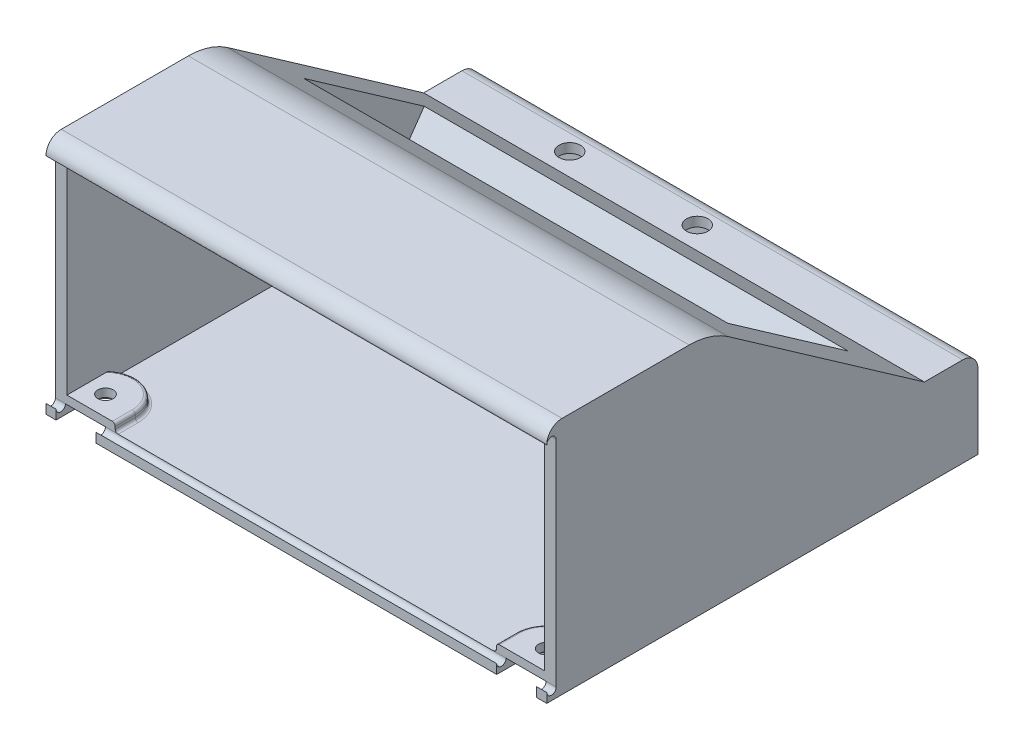
from build123d import *

# Parameters (mm, degrees)
BOSS_EXTRUDE1_DEPTH = 85
CUT_EXTRUDE1_START  = 1.95
CUT_EXTRUDE1_DEPTH  = 81.1
CUT_EXTRUDE5_REACH  = 51.22
SKETCH5_W           = 72
SKETCH5_H           = 25
SKETCH5_3_W         = 78
SKETCH5_3_H         = 31
SKETCH5_3_W_2       = 72
SKETCH5_3_H_2       = 25
BOSS_EXTRUDE3_DEPTH = 5.6
SKETCH6_R           = 1.825
CUT_EXTRUDE6_DEPTH  = 13.6
CUT_EXTRUDE7_REACH  = 87
SKETCH12_R          = 1.5
CUT_EXTRUDE10_DEPTH = 1.6
SKETCH12_5_R        = 1.5
SKETCH12_5_R_2      = 1.3
BOSS_EXTRUDE7_DEPTH = 3
SKETCH12_6_R        = 1.5
SKETCH12_6_R_2      = 1.3
CUT_EXTRUDE11_DEPTH = 1.6
CUT_EXTRUDE8_REACH  = 87
FILLET2_R           = 0.5


with BuildPart() as part:
    # Sketch1 → Boss-Extrude1 (new body)
    with BuildSketch(Plane(origin=(0, 0, 0), x_dir=(0, 0, -1), z_dir=(1, 0, 0))):
        with BuildLine():
            Line((-22.930528586, 36.4), (-22.930528586, -1.6))
            Line((-22.930528586, -1.6), (50.269471414, -1.6))
            Line((50.269471414, -1.6), (50.269471414, 11))
            ThreePointArc((50.269471414, 11), (49.507949045, 12.838477631), (47.669471414, 13.6))
            Line((47.669471414, 13.6), (41.173949476, 13.6))
            Line((41.173949476, 13.6), (7.895010815, 36.902163714))
            ThreePointArc((7.895010815, 36.902163714), (4.729711428, 38.463116629), (1.241524153, 39))
            Line((1.241524153, 39), (-20.330528586, 39))
            ThreePointArc((-20.330528586, 39), (-22.169006218, 38.238477631), (-22.930528586, 36.4))
        make_face()
    extrude(amount=BOSS_EXTRUDE1_DEPTH)

    # Sketch1_3 → Cut-Extrude1 (cut)
    with BuildSketch(Plane(origin=(0, 0, 0), x_dir=(0, 0, -1), z_dir=(1, 0, 0)).offset(CUT_EXTRUDE1_START)):
        with BuildLine():
            Line((48.669471414, 0), (48.669471414, 11))
            ThreePointArc((48.669471414, 11), (48.376578195, 11.707106781), (47.669471414, 12))
            Line((47.669471414, 12), (40.669471414, 12))
            Line((40.669471414, 12), (6.977288517, 35.591520443))
            ThreePointArc((6.977288517, 35.591520443), (4.248582149, 36.937169507), (1.241524153, 37.4))
            Line((1.241524153, 37.4), (-20.330528586, 37.4))
            ThreePointArc((-20.330528586, 37.4), (-21.037635368, 37.107106781), (-21.330528586, 36.4))
            Line((-21.330528586, 36.4), (-21.330528586, 0))
            Line((-21.330528586, 0), (48.669471414, 0))
        make_face()
    extrude(amount=CUT_EXTRUDE1_DEPTH, mode=Mode.SUBTRACT)

    # Sketch5 → Cut-Extrude5 (cut, up to next)
    with BuildSketch(Plane(origin=(0, 28.47116522, -19.935724509), x_dir=(1, 0, 0), z_dir=(0, 0.819152044, -0.573576436)), mode=Mode.PRIVATE) as cut_extrude5_sk1:
        with Locations((42.5, 5.614044021)):
            Rectangle(SKETCH5_W, SKETCH5_H)
    cut_extrude5_tool1 = extrude(cut_extrude5_sk1.sketch, amount=-CUT_EXTRUDE5_REACH, mode=Mode.PRIVATE) & part.part
    add(cut_extrude5_tool1.solids().sort_by_distance((42.5, 25.251082, -24.53448))[0], mode=Mode.SUBTRACT)

    # Sketch5_3 → Boss-Extrude3 (add)
    with BuildSketch(Plane(origin=(0, 28.47116522, -19.935724509), x_dir=(1, 0, 0), z_dir=(0, 0.819152044, -0.573576436))):
        with Locations((42.5, 5.614044021)):
            Rectangle(SKETCH5_3_W, SKETCH5_3_H)
        with Locations((42.5, 5.614044021)):
            Rectangle(SKETCH5_3_W_2, SKETCH5_3_H_2, mode=Mode.SUBTRACT)
    extrude(amount=-BOSS_EXTRUDE3_DEPTH)

    # Sketch6 → Cut-Extrude6 (cut)
    with BuildSketch(Plane(origin=(0, 13.6, 0), x_dir=(1, 0, 0), z_dir=(0, 1, 0))):
        with Locations((21, 44.969471414)):
            Circle(SKETCH6_R)
        with Locations((42.65, 44.969471414)):
            Circle(SKETCH6_R)
    extrude(amount=-CUT_EXTRUDE6_DEPTH, mode=Mode.SUBTRACT)

    # Sketch7 → Cut-Extrude7 (cut, up to next)
    with BuildSketch(Plane.ZY, mode=Mode.PRIVATE) as cut_extrude7_sk1:
        with BuildLine():
            Line((-12.869471414, 15.725), (-5.319471414, 15.725))
            ThreePointArc((-5.319471414, 15.725), (-4.753785989, 15.490685425), (-4.519471414, 14.925))
            Line((-4.519471414, 14.925), (-4.519471414, 13.075))
            ThreePointArc((-4.519471414, 13.075), (-4.753785989, 12.509314575), (-5.319471414, 12.275))
            Line((-5.319471414, 12.275), (-12.869471414, 12.275))
            ThreePointArc((-12.869471414, 12.275), (-13.435156838, 12.509314575), (-13.669471414, 13.075))
            Line((-13.669471414, 13.075), (-13.669471414, 14.925))
            ThreePointArc((-13.669471414, 14.925), (-13.435156838, 15.490685425), (-12.869471414, 15.725))
        make_face()
    cut_extrude7_tool1 = extrude(cut_extrude7_sk1.sketch, amount=-CUT_EXTRUDE7_REACH, mode=Mode.PRIVATE) & part.part
    add(cut_extrude7_tool1.solids().sort_by_distance((0, 14, -9.094471))[0], mode=Mode.SUBTRACT)

    # Sketch12 → Cut-Extrude10 (cut)
    with BuildSketch(Plane.XZ.offset(1.6)):
        with Locations((79.9, 17.930528586)):
            Circle(SKETCH12_R)
        with Locations((5.1, 17.930528586)):
            Circle(SKETCH12_R)
    extrude(amount=-CUT_EXTRUDE10_DEPTH, mode=Mode.SUBTRACT)

    # Sketch12_5 → Boss-Extrude7 (add)
    with BuildSketch(Plane.XZ.offset(1.6)):
        with BuildLine():
            ThreePointArc((83.3, 17.930528586), (79.9, 14.530528586), (76.5, 17.930528586))
            Line((76.5, 17.930528586), (76.5, 22.930528586))
            Line((76.5, 22.930528586), (74.85, 22.930528586))
            Line((74.85, 22.930528586), (74.85, 17.930528586))
            ThreePointArc((74.85, 17.930528586), (79.9, 12.880528586), (84.95, 17.930528586))
            Line((84.95, 17.930528586), (84.95, 22.930528586))
            Line((84.95, 22.930528586), (83.3, 22.930528586))
            Line((83.3, 22.930528586), (83.3, 17.930528586))
        make_face()
        with BuildLine():
            Line((76.5, 22.930528586), (76.5, 17.930528586))
            ThreePointArc((76.5, 17.930528586), (79.9, 14.530528586), (83.3, 17.930528586))
            Line((83.3, 17.930528586), (83.3, 22.930528586))
            Line((83.3, 22.930528586), (76.5, 22.930528586))
        make_face()
        with Locations((79.9, 17.930528586)):
            Circle(SKETCH12_5_R, mode=Mode.SUBTRACT)
        with Locations((79.9, 17.930528586)):
            Circle(SKETCH12_5_R)
        with Locations((79.9, 17.930528586)):
            Circle(SKETCH12_5_R_2, mode=Mode.SUBTRACT)
        with BuildLine():
            Line((10.15, 17.930528586), (10.15, 22.930528586))
            Line((10.15, 22.930528586), (8.5, 22.930528586))
            Line((8.5, 22.930528586), (8.5, 17.930528586))
            ThreePointArc((8.5, 17.930528586), (5.1, 14.530528586), (1.7, 17.930528586))
            Line((1.7, 17.930528586), (1.7, 22.930528586))
            Line((1.7, 22.930528586), (0.05, 22.930528586))
            Line((0.05, 22.930528586), (0.05, 17.930528586))
            ThreePointArc((0.05, 17.930528586), (5.1, 12.880528586), (10.15, 17.930528586))
        make_face()
        with BuildLine():
            Line((8.5, 17.930528586), (8.5, 22.930528586))
            Line((8.5, 22.930528586), (1.7, 22.930528586))
            Line((1.7, 22.930528586), (1.7, 17.930528586))
            ThreePointArc((1.7, 17.930528586), (5.1, 14.530528586), (8.5, 17.930528586))
        make_face()
        with Locations((5.1, 17.930528586)):
            Circle(SKETCH12_5_R, mode=Mode.SUBTRACT)
        with Locations((5.1, 17.930528586)):
            Circle(SKETCH12_5_R)
        with Locations((5.1, 17.930528586)):
            Circle(SKETCH12_5_R_2, mode=Mode.SUBTRACT)
    extrude(amount=-BOSS_EXTRUDE7_DEPTH)

    # Sketch12_6 → Cut-Extrude11 (cut)
    with BuildSketch(Plane.XZ.offset(1.6)):
        with BuildLine():
            Line((8.5, 17.930528586), (8.5, 22.930528586))
            Line((8.5, 22.930528586), (1.7, 22.930528586))
            Line((1.7, 22.930528586), (1.7, 17.930528586))
            ThreePointArc((1.7, 17.930528586), (5.1, 14.530528586), (8.5, 17.930528586))
        make_face()
        with Locations((5.1, 17.930528586)):
            Circle(SKETCH12_6_R, mode=Mode.SUBTRACT)
        with BuildLine():
            Line((76.5, 22.930528586), (76.5, 17.930528586))
            ThreePointArc((76.5, 17.930528586), (79.9, 14.530528586), (83.3, 17.930528586))
            Line((83.3, 17.930528586), (83.3, 22.930528586))
            Line((83.3, 22.930528586), (76.5, 22.930528586))
        make_face()
        with Locations((79.9, 17.930528586)):
            Circle(SKETCH12_6_R, mode=Mode.SUBTRACT)
        with Locations((79.9, 17.930528586)):
            Circle(SKETCH12_6_R)
        with Locations((79.9, 17.930528586)):
            Circle(SKETCH12_6_R_2, mode=Mode.SUBTRACT)
        with Locations((5.1, 17.930528586)):
            Circle(SKETCH12_6_R)
        with Locations((5.1, 17.930528586)):
            Circle(SKETCH12_6_R_2, mode=Mode.SUBTRACT)
    extrude(amount=-CUT_EXTRUDE11_DEPTH, mode=Mode.SUBTRACT)

    # Sketch9 → Cut-Extrude8 (cut, up to next)
    with BuildSketch(Plane(origin=(0, 0, 0), x_dir=(0, 0, -1), z_dir=(1, 0, 0)), mode=Mode.PRIVATE) as cut_extrude8_sk1:
        with BuildLine():
            Line((-21.330528586, 35.411275227), (-21.330528586, 0))
            ThreePointArc((-21.330528586, 0), (-22.1361662, -0.794362387), (-22.930528586, 0.011275227))
            Line((-22.930528586, 0.011275227), (-22.930528586, 36.4))
            ThreePointArc((-22.930528586, 36.4), (-22.130528586, 37.2), (-21.330528586, 36.4))
            Line((-21.330528586, 36.4), (-21.330528586, 35.411275227))
        make_face()
    cut_extrude8_tool1 = extrude(cut_extrude8_sk1.sketch, amount=CUT_EXTRUDE8_REACH, mode=Mode.PRIVATE) & part.part
    add(cut_extrude8_tool1.solids().sort_by_distance((0, 18.202803, 22.130529))[0], mode=Mode.SUBTRACT)

    # Fillet2
    fillet2_edges = [part.edges().sort_by_distance(p)[0] for p in [
        (74.85, 0, 19.630528586),
        (77.709680389, 0, 13.380253869),
        (77.709680389, 1.4, 13.380253869),
        (74.85, 1.4, 19.630528586),
        (7.290319611, 0, 13.380253869),
        (10.15, 1.4, 19.630528586),
        (10.15, 0, 19.630528586),
        (7.290319611, 1.4, 13.380253869),
    ]]
    fillet(fillet2_edges, radius=FILLET2_R)


solid = part.part
